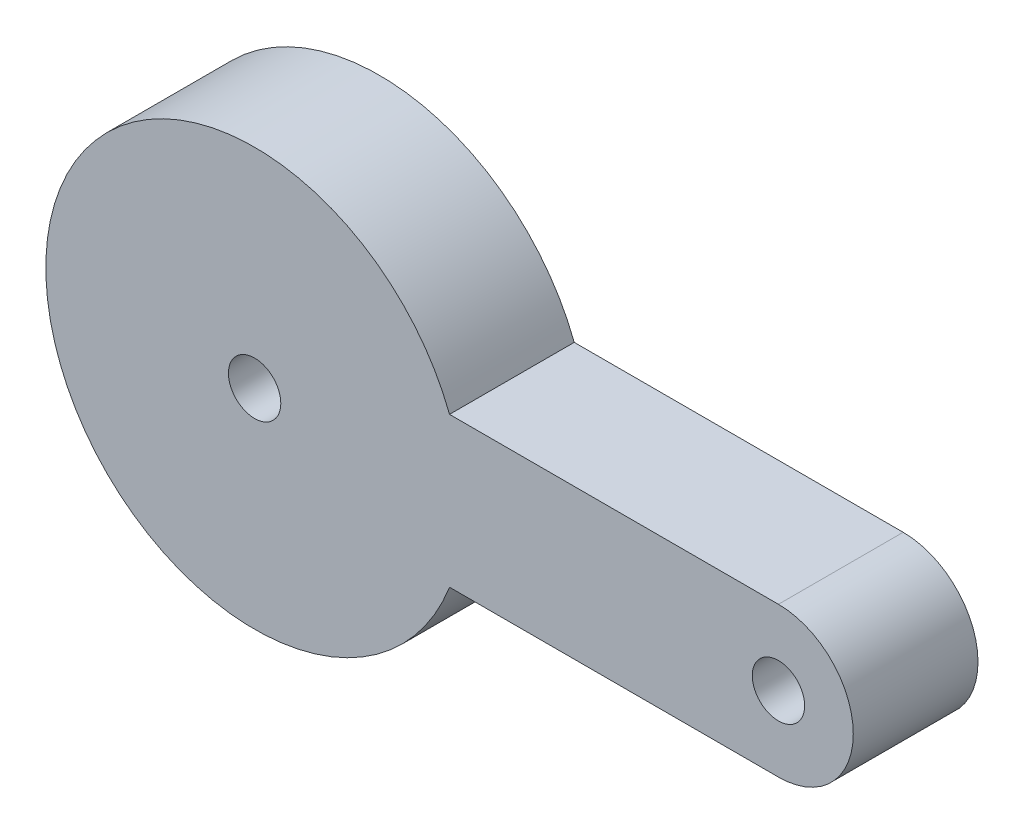
from build123d import *

# Parameters (mm, degrees)
SKETCH1_R           = 1.75
BOSS_EXTRUDE1_DEPTH = 8.333333333


with BuildPart() as part:
    # Sketch1 → Boss-Extrude1 (new body)
    with BuildSketch(Plane.XY):
        with BuildLine():
            Line((35, 5), (13.02315246, 5))
            ThreePointArc((13.02315246, 5), (-13.95, 0), (13.02315246, -5))
            Line((13.02315246, -5), (35, -5))
            ThreePointArc((35, -5), (40, 0), (35, 5))
        make_face()
        Circle(SKETCH1_R, mode=Mode.SUBTRACT)
        with Locations((35, 0)):
            Circle(SKETCH1_R, mode=Mode.SUBTRACT)
    extrude(amount=BOSS_EXTRUDE1_DEPTH)


solid = part.part
